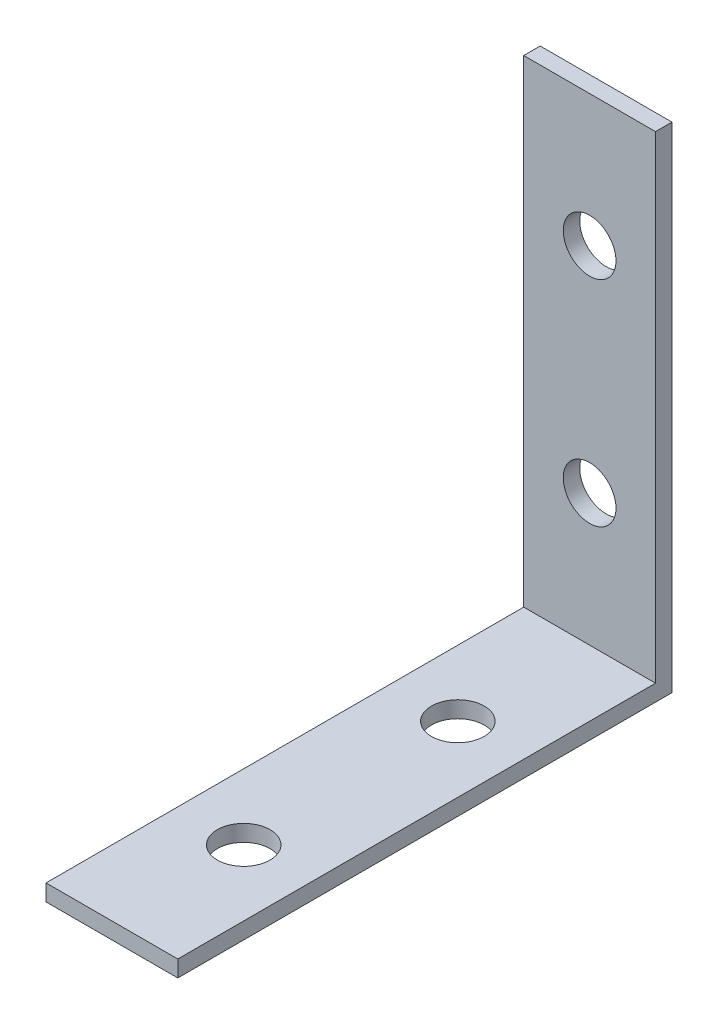
from build123d import *

# Parameters (mm, degrees)
SKETCH1_W           = 20
SKETCH1_H           = 75
BOSS_EXTRUDE1_DEPTH = 2.5
SKETCH2_W           = 20
SKETCH2_H           = 2.5
BOSS_EXTRUDE2_DEPTH = 72.5
SKETCH3_R           = 4
CUT_EXTRUDE1_DEPTH  = 2.5
SKETCH4_R           = 4
CUT_EXTRUDE2_DEPTH  = 2.5


with BuildPart() as part:
    # Sketch1 → Boss-Extrude1 (new body)
    with BuildSketch(Plane(origin=(0, 0, 0), x_dir=(1, 0, 0), z_dir=(0, 1, 0))):
        Rectangle(SKETCH1_W, SKETCH1_H)
    extrude(amount=BOSS_EXTRUDE1_DEPTH)

    # Sketch2 → Boss-Extrude2 (add)
    with BuildSketch(Plane(origin=(0, 2.5, 0), x_dir=(1, 0, 0), z_dir=(0, 1, 0))):
        with Locations((0, 36.25)):
            Rectangle(SKETCH2_W, SKETCH2_H)
    extrude(amount=BOSS_EXTRUDE2_DEPTH)

    # Sketch3 → Cut-Extrude1 (cut)
    with BuildSketch(Plane(origin=(0, 2.5, 0), x_dir=(1, 0, 0), z_dir=(0, 1, 0))):
        with Locations((0, 15)):
            Circle(SKETCH3_R)
        with Locations((0, -17.5)):
            Circle(SKETCH3_R)
    extrude(amount=-CUT_EXTRUDE1_DEPTH, mode=Mode.SUBTRACT)

    # Sketch4 → Cut-Extrude2 (cut)
    with BuildSketch(Plane.XY.offset(-35)):
        with Locations((0, 55)):
            Circle(SKETCH4_R)
        with Locations((0, 22.5)):
            Circle(SKETCH4_R)
    extrude(amount=-CUT_EXTRUDE2_DEPTH, mode=Mode.SUBTRACT)


solid = part.part
